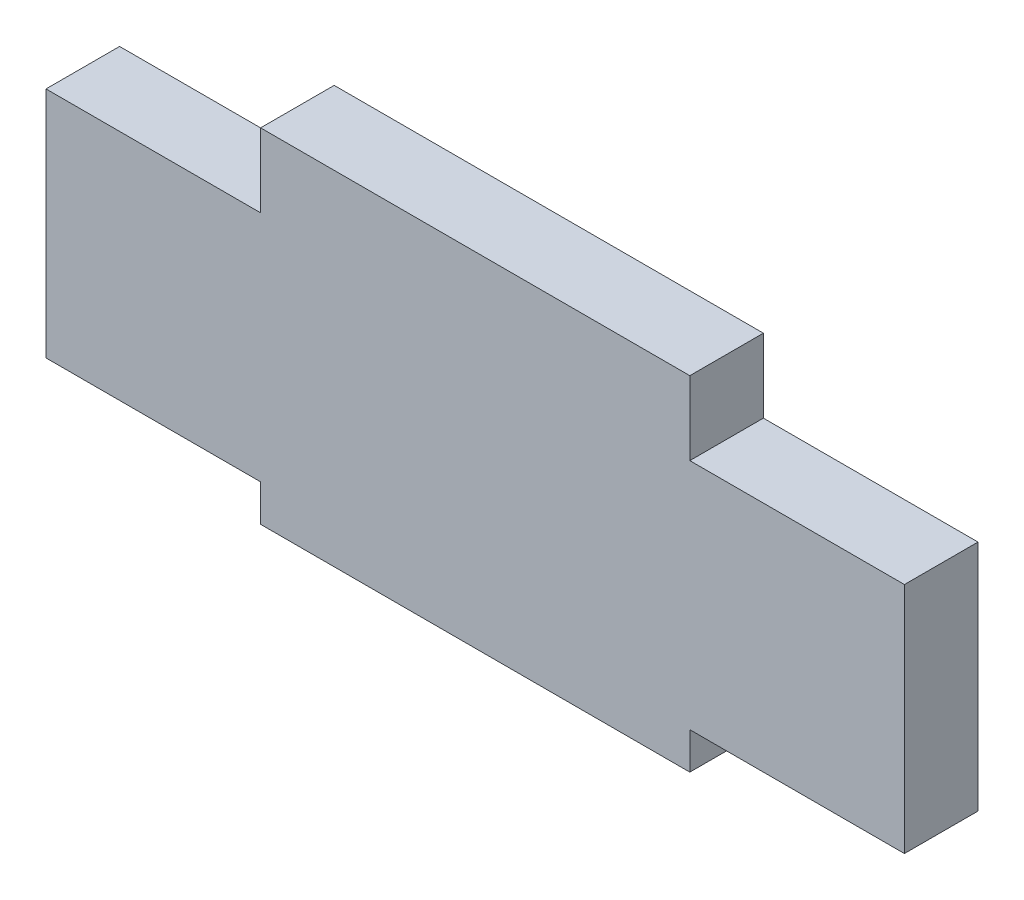
from build123d import *

# Parameters (mm, degrees)
ESBO_O1_W                = 70
ESBO_O1_H                = 19
ESBO_O1_W_2              = 35
ESBO_O1_H_2              = 6
ESBO_O1_H_3              = 3
RESSALTO_EXTRUS_O1_DEPTH = 6


with BuildPart() as part:
    # Esboço1 → Ressalto-extrusão1 (new body)
    with BuildSketch(Plane.XY):
        Rectangle(ESBO_O1_W, ESBO_O1_H)
        with Locations((0, 12.5)):
            Rectangle(ESBO_O1_W_2, ESBO_O1_H_2)
        with Locations((0, -11)):
            Rectangle(ESBO_O1_W_2, ESBO_O1_H_3)
    extrude(amount=RESSALTO_EXTRUS_O1_DEPTH)


solid = part.part
